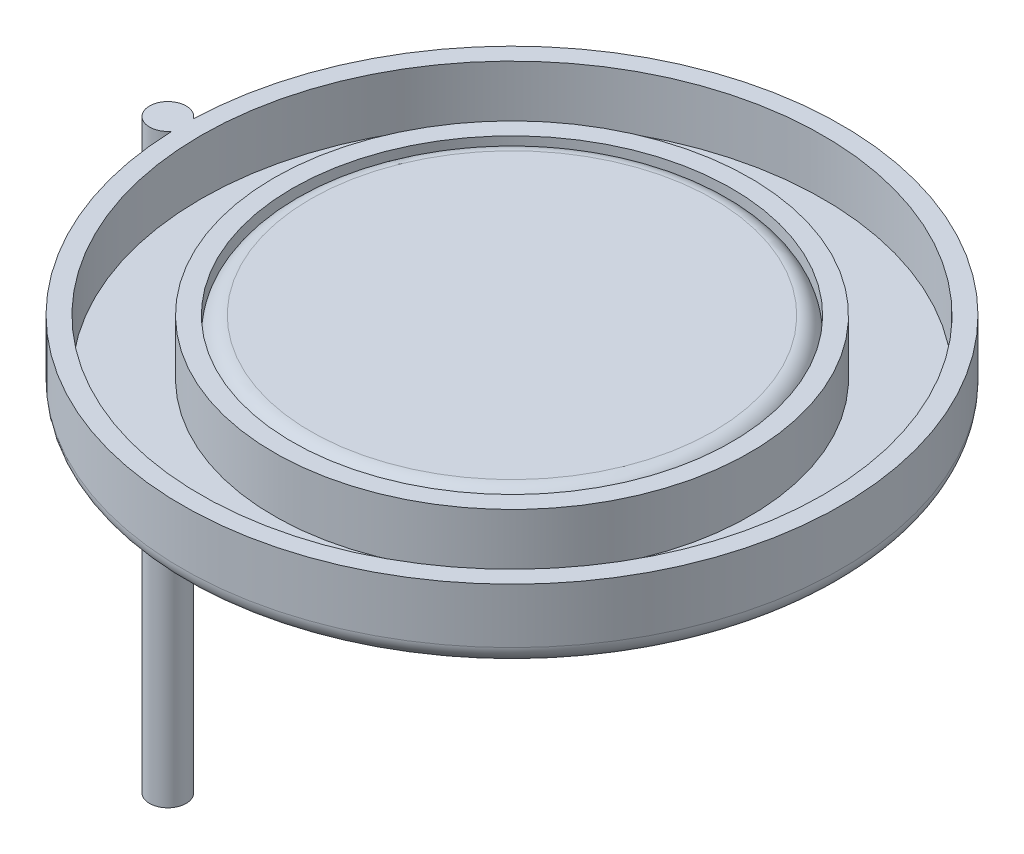
from build123d import *

# Parameters (mm, degrees)
SKETCH3_R      = 0.25
EXTRUDE1_DEPTH = 8


with BuildPart() as part:
    # Sketch3 → Extrude1 (new body)
    with BuildSketch(Plane(origin=(0, 1, 0), x_dir=(1, 0, 0), z_dir=(0, 1, 0))):
        with Locations((-4.7, 0)):
            Circle(SKETCH3_R)
    extrude(amount=-EXTRUDE1_DEPTH)



with BuildPart() as body_2:
    # Sketch2 → Revolve-Thin1 (revolve)
    with BuildSketch(Plane(origin=(0, 0, 0), x_dir=(-1, 0, 0), z_dir=(0, 0, 1))):
        with BuildLine():
            Line((-3, 0), (-3, -0.75))
            ThreePointArc((-3, -0.75), (-2.926776695, -0.926776695), (-2.75, -1))
            Line((-2.75, -1), (0, -1))
            Line((0, -1), (0, -0.75))
            Line((0, -0.75), (-2.75, -0.75))
            Line((-2.75, -0.75), (-2.75, 0))
            Line((-2.75, 0), (-3, 0))
        make_face()
    revolve(axis=Axis((0, -0.05, 0), (0, 1, 0)))


with BuildPart() as part_1:
    add(part.part)

    add(body_2.part)  # Revolve-Thin2 merges body 2
    # Sketch1 → Revolve-Thin2 (revolve)
    with BuildSketch(Plane.XY):
        with BuildLine():
            Line((-4.5, 1), (-4.5, 0.25))
            ThreePointArc((-4.5, 0.25), (-4.426776695, 0.073223305), (-4.25, 0))
            Line((-4.25, 0), (-3.25, 0))
            ThreePointArc((-3.25, 0), (-3.073223305, 0.073223305), (-3, 0.25))
            Line((-3, 0.25), (-3, 1))
            Line((-3, 1), (-3.25, 1))
            Line((-3.25, 1), (-3.25, 0.25))
            Line((-3.25, 0.25), (-4.25, 0.25))
            Line((-4.25, 0.25), (-4.25, 1))
            Line((-4.25, 1), (-4.5, 1))
        make_face()
    revolve(axis=Axis((0, 1.05, 0), (0, -1, 0)))


solid = part_1.part
